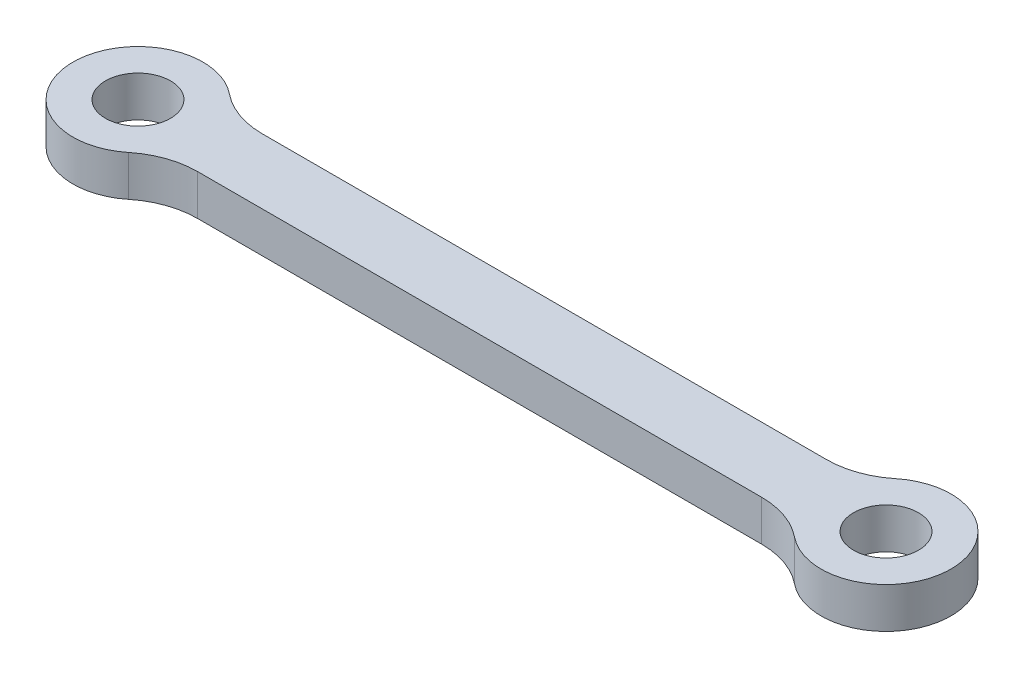
from build123d import *

# Parameters (mm, degrees)
SKETCH1_R           = 4
BOSS_EXTRUDE1_DEPTH = 5
FILLET1_R           = 10
SCALE1_SCALE        = 0.5


with BuildPart() as part:
    # Sketch1 → Boss-Extrude1 (new body)
    with BuildSketch(Plane(origin=(0, 0, 0), x_dir=(1, 0, 0), z_dir=(0, 1, 0))):
        with BuildLine():
            Line((39.07179677, -4), (-39.07179677, -4))
            ThreePointArc((-39.07179677, -4), (-54, 0), (-39.07179677, 4))
            Line((-39.07179677, 4), (39.07179677, 4))
            ThreePointArc((39.07179677, 4), (54, 0), (39.07179677, -4))
        make_face()
        with Locations((-46, 0)):
            Circle(SKETCH1_R, mode=Mode.SUBTRACT)
        with Locations((46, 0)):
            Circle(SKETCH1_R, mode=Mode.SUBTRACT)
    extrude(amount=BOSS_EXTRUDE1_DEPTH)

    # Fillet1
    fillet1_edges = [part.edges().sort_by_distance(p)[0] for p in [
        (-39.07179677, 2.5, -4),
        (39.07179677, 2.5, -4),
        (39.07179677, 2.5, 4),
        (-39.07179677, 2.5, 4),
    ]]
    fillet(fillet1_edges, radius=FILLET1_R)


with BuildPart() as part_1:
    # Scale1: scaled about (0, 2.5, 0)
    add(part.part.scale(SCALE1_SCALE).moved(Location((0, 1.25, 0))))


solid = part_1.part
